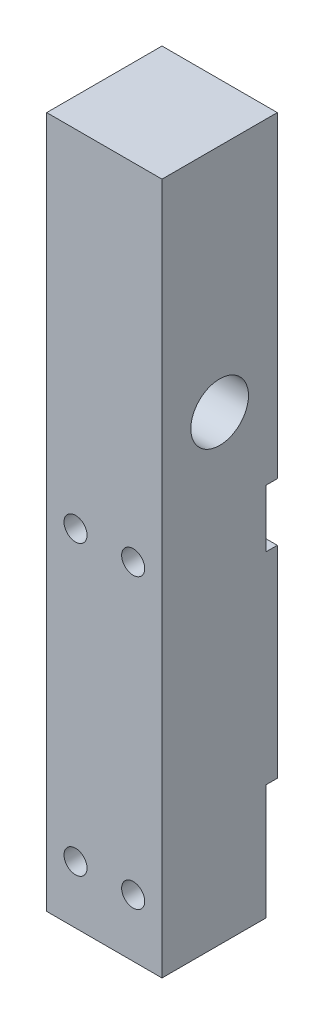
from build123d import *

# Parameters (mm, degrees)
SKETCH1_W           = 20
SKETCH1_H           = 120
SKETCH1_R           = 2.5
BOSS_EXTRUDE2_DEPTH = 20
SKETCH10_R          = 5
CUT_EXTRUDE1_DEPTH  = 10
SKETCH11_R          = 1
CUT_EXTRUDE2_DEPTH  = 124.288280059
SKETCH12_R          = 2
CUT_EXTRUDE3_DEPTH  = 5
SKETCH11_3_R        = 1
CUT_EXTRUDE4_DEPTH  = 124.288280059
SKETCH14_W          = 20
SKETCH14_H          = 10
SKETCH14_H_2        = 20
CUT_EXTRUDE6_DEPTH  = 2


with BuildPart() as part:
    # Sketch1 → Boss-Extrude2 (new body)
    with BuildSketch(Plane(origin=(0, 0, 0), x_dir=(0, 0, -1), z_dir=(1, 0, 0))):
        with Locations((10, 60)):
            Rectangle(SKETCH1_W, SKETCH1_H)
        with Locations((10, 80)):
            Circle(SKETCH1_R, mode=Mode.SUBTRACT)
    extrude(amount=-BOSS_EXTRUDE2_DEPTH)

    # Sketch10 → Cut-Extrude1 (cut)
    with BuildSketch(Plane(origin=(0, 0, 0), x_dir=(0, 0, -1), z_dir=(1, 0, 0))):
        with Locations((10, 80)):
            Circle(SKETCH10_R)
    extrude(amount=-CUT_EXTRUDE1_DEPTH, mode=Mode.SUBTRACT)

    # Sketch11 → Cut-Extrude2 (cut, through all)
    with BuildSketch(Plane.XY):
        with Locations((-15, 10)):
            Circle(SKETCH11_R)
        with Locations((-5, 10)):
            Circle(SKETCH11_R)
    extrude(amount=-CUT_EXTRUDE2_DEPTH, mode=Mode.SUBTRACT)

    # Sketch12 → Cut-Extrude3 (cut)
    with BuildSketch(Plane.XY):
        with Locations((-15, 10)):
            Circle(SKETCH12_R)
        with Locations((-5, 10)):
            Circle(SKETCH12_R)
        with Locations((-15, 60)):
            Circle(SKETCH12_R)
        with Locations((-5, 60)):
            Circle(SKETCH12_R)
    extrude(amount=-CUT_EXTRUDE3_DEPTH, mode=Mode.SUBTRACT)

    # Sketch11_3 → Cut-Extrude4 (cut, through all)
    with BuildSketch(Plane.XY):
        with Locations((-15, 60)):
            Circle(SKETCH11_3_R)
        with Locations((-5, 60)):
            Circle(SKETCH11_3_R)
    extrude(amount=-CUT_EXTRUDE4_DEPTH, mode=Mode.SUBTRACT)

    # Sketch14 → Cut-Extrude6 (cut)
    with BuildSketch(Plane(origin=(0, 0, -20), x_dir=(-1, 0, 0), z_dir=(0, 0, -1))):
        with Locations((10, 60)):
            Rectangle(SKETCH14_W, SKETCH14_H)
        with Locations((10, 10)):
            Rectangle(SKETCH14_W, SKETCH14_H_2)
    extrude(amount=-CUT_EXTRUDE6_DEPTH, mode=Mode.SUBTRACT)


solid = part.part
